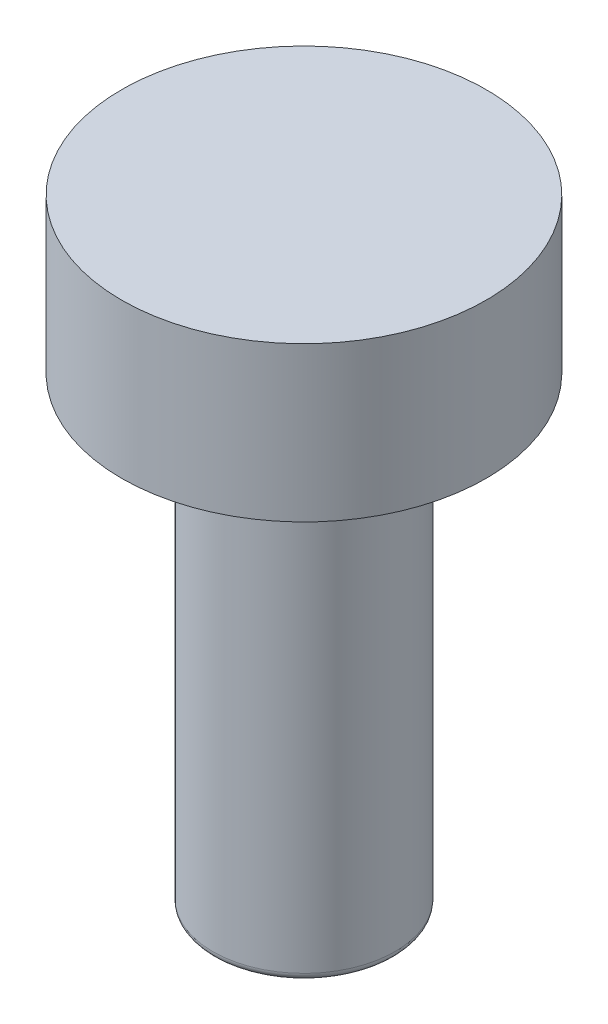
from build123d import *

# Parameters (mm, degrees)
BOSS_EXTRUDE1_DEPTH = 15.24
SKETCH2_R           = 6
BOSS_EXTRUDE2_DEPTH = 5.08
FILLET1_R           = 0.254


with BuildPart() as part:
    # Sketch1 → Boss-Extrude1 (new body)
    with BuildSketch(Plane(origin=(0, 0, 0), x_dir=(1, 0, 0), z_dir=(0, 1, 0))):
        with BuildLine():
            Line((-1.658312395, 2.5), (1.658312395, 2.5))
            ThreePointArc((1.658312395, 2.5), (0, -3), (-1.658312395, 2.5))
        make_face()
    extrude(amount=BOSS_EXTRUDE1_DEPTH)

    # Sketch2 → Boss-Extrude2 (add)
    with BuildSketch(Plane(origin=(0, 15.24, 0), x_dir=(1, 0, 0), z_dir=(0, 1, 0))):
        Circle(SKETCH2_R)
    extrude(amount=BOSS_EXTRUDE2_DEPTH)

    # Fillet1
    fillet1_edges = [part.edges().sort_by_distance(p)[0] for p in [
        (0, 0, 3),
    ]]
    fillet(fillet1_edges, radius=FILLET1_R)


solid = part.part
